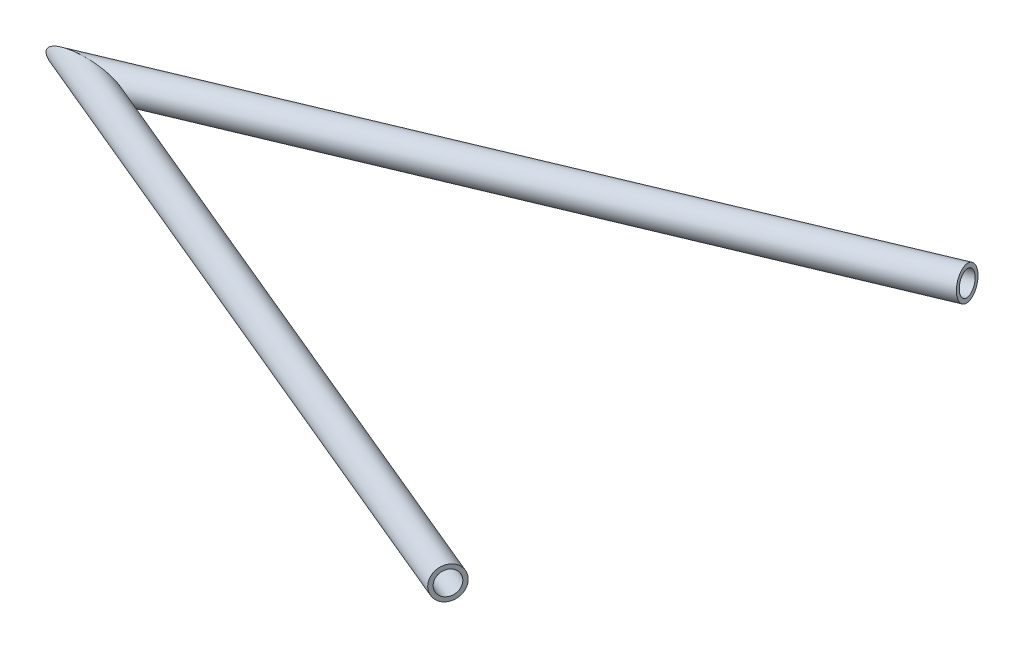
from build123d import *

# Parameters (mm, degrees)
SKETCH1_ON_SEGMENT_1_R                         = 9.525
SKETCH1_ON_SEGMENT_1_R_2                       = 6.985
PIPE_STANDARD_S40_PIPE_1_SCH_40_1_DEPTH        = 520.177339385
SKETCH1_R                                      = 9.525
SKETCH1_R_2                                    = 6.985
PIPE_STANDARD_S40_PIPE_1_SCH_40_1_2_DEPTH      = 452.035839287
PIPE_STANDARD_S40_PIPE_1_SCH_40_1_2_DEPTH_BACK = 37.438610879


with BuildPart() as part:
    # Sketch1 on segment 1 (carried to segment 1) → Pipe standard s40 PIPE 1 SCH 40_1 (new body)
    with BuildSketch(Plane(origin=(435, 47.900944559, 206.8), x_dir=(-0.413447533, -0.145324098, 0.898855964), z_dir=(-0.898855964, -0.092416188, -0.42838908))):
        Circle(SKETCH1_ON_SEGMENT_1_R)
        Circle(SKETCH1_ON_SEGMENT_1_R_2, mode=Mode.SUBTRACT)
    extrude(amount=PIPE_STANDARD_S40_PIPE_1_SCH_40_1_DEPTH)

    # Pipe standard s40 PIPE 1 SCH 40_1 mitre
    split(bisect_by=Plane(origin=(1.087414829, 3.28807164, 0), x_dir=(0, -0.999958714, -0.009086796), z_dir=(-0.088036608, -0.009051514, 0.996076114)), keep=Keep.TOP)


with BuildPart() as body_2:
    # Sketch1 → Pipe standard s40 PIPE 1 SCH 40_1 2 (new, two sides)
    with BuildSketch(Plane(origin=(1.087414829, 3.28807164, 0), x_dir=(-0.2491636735910112, -0.12843319629111516, -0.9599074840072245), z_dir=(0.9599074840072245, 0.09869322084943591, -0.2623685772063502))) as pipe_standard_s40_pipe_1_sch_40_1_2_sk:
        Circle(SKETCH1_R)
        Circle(SKETCH1_R_2, mode=Mode.SUBTRACT)
    extrude(amount=PIPE_STANDARD_S40_PIPE_1_SCH_40_1_2_DEPTH)
    extrude(pipe_standard_s40_pipe_1_sch_40_1_2_sk.sketch, amount=-PIPE_STANDARD_S40_PIPE_1_SCH_40_1_2_DEPTH_BACK)

    # Pipe standard s40 PIPE 1 SCH 40_1 2 mitr
    split(bisect_by=Plane(origin=(1.087414829, 3.28807164, 0), x_dir=(0, 0.999958714, 0.009086796), z_dir=(0.088036608, 0.009051514, -0.996076114)), keep=Keep.TOP)


solid = Compound([part.part, body_2.part])
